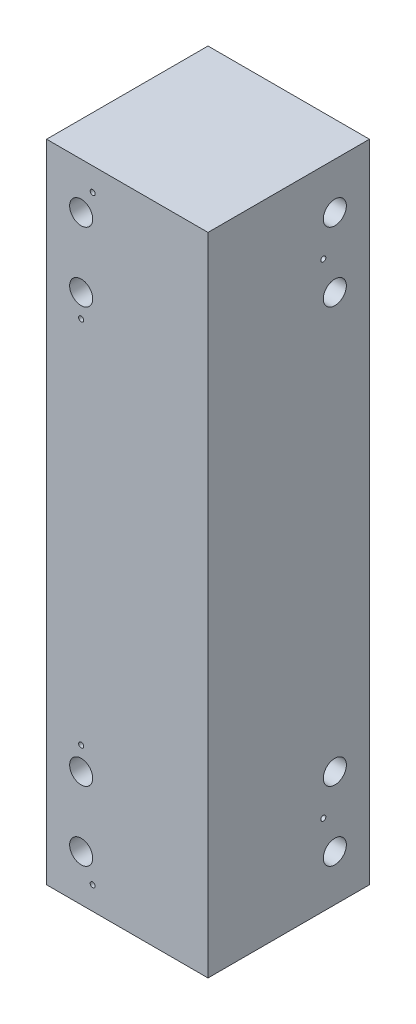
from build123d import *

# Parameters (mm, degrees)
SKETCH1_W                                = 88.9
SKETCH1_H                                = 88.9
BOSS_EXTRUDE1_DEPTH                      = 355.6
SKETCH2_R                                = 1.3890625
CUT_EXTRUDE1_DEPTH                       = 1
CUT_EXTRUDE1_DEPTH_BACK                  = 89.9
SKETCH3_R                                = 1.3890625
CUT_EXTRUDE2_DEPTH                       = 1
CUT_EXTRUDE2_DEPTH_BACK                  = 89.9
F_1_2_0_5_DIAMETER_HOLE1_D               = 12.7
F_1_2_0_5_DIAMETER_HOLE1_DEPTH           = 19.05
F_1_2_0_5_DIAMETER_HOLE1_TIP             = 3.815464931
F_1_2_0_5_DIAMETER_HOLE1_ON_FACE_2_D     = 12.7
F_1_2_0_5_DIAMETER_HOLE1_ON_FACE_2_DEPTH = 19.05
F_1_2_0_5_DIAMETER_HOLE1_ON_FACE_2_TIP   = 3.815464931
F_10_0_1935_DIAMETER_HOLE1_D             = 4.9149
F_10_0_1935_DIAMETER_HOLE1_DEPTH         = 50.8
F_10_0_1935_DIAMETER_HOLE1_TIP           = 1.476584928


with BuildPart() as part:
    # Sketch1 → Boss-Extrude1 (new body)
    with BuildSketch(Plane(origin=(0, 0, 0), x_dir=(1, 0, 0), z_dir=(0, 1, 0))):
        with Locations((44.45, -44.45)):
            Rectangle(SKETCH1_W, SKETCH1_H)
    extrude(amount=BOSS_EXTRUDE1_DEPTH)

    # Sketch2 → Cut-Extrude1 (cut, two sides)
    with BuildSketch(Plane.XY.offset(88.9)) as cut_extrude1_sk:
        with Locations((19.05, 76.2)):
            Circle(SKETCH2_R)
        with Locations((19.05, 279.4)):
            Circle(SKETCH2_R)
        with Locations((25.4, 342.9)):
            Circle(SKETCH2_R)
        with Locations((25.4, 12.7)):
            Circle(SKETCH2_R)
    extrude(amount=CUT_EXTRUDE1_DEPTH, mode=Mode.SUBTRACT)
    extrude(cut_extrude1_sk.sketch, amount=-CUT_EXTRUDE1_DEPTH_BACK, mode=Mode.SUBTRACT)

    # Sketch3 → Cut-Extrude2 (cut, two sides)
    with BuildSketch(Plane.ZY) as cut_extrude2_sk:
        with Locations((25.4, 311.15)):
            Circle(SKETCH3_R)
        with Locations((25.4, 44.45)):
            Circle(SKETCH3_R)
    extrude(amount=CUT_EXTRUDE2_DEPTH, mode=Mode.SUBTRACT)
    extrude(cut_extrude2_sk.sketch, amount=-CUT_EXTRUDE2_DEPTH_BACK, mode=Mode.SUBTRACT)

    # 1/2 (0.5) Diameter Hole1
    with Locations(Plane(origin=(19.05, 292.1, 88.9), x_dir=(1, 0, 0), z_dir=(0, 0, 1))):
        with Locations((0, 0), (0, 38.1), (0, -266.7), (0, -228.6)):
            Hole(F_1_2_0_5_DIAMETER_HOLE1_D / 2, depth=F_1_2_0_5_DIAMETER_HOLE1_DEPTH)
            with Locations((0, 0, -(F_1_2_0_5_DIAMETER_HOLE1_DEPTH + F_1_2_0_5_DIAMETER_HOLE1_TIP / 2))):  # 118° drill point
                Cone(0, F_1_2_0_5_DIAMETER_HOLE1_D / 2, F_1_2_0_5_DIAMETER_HOLE1_TIP, mode=Mode.SUBTRACT)

    # 1/2 (0.5) Diameter Hole1 on face 2
    with Locations(Plane(origin=(88.9, 63.5, 19.05), x_dir=(0, 0, 1), z_dir=(1, 0, 0))):
        with Locations((0, 0), (0, 38.1), (0, -266.7), (0, -228.6)):
            Hole(F_1_2_0_5_DIAMETER_HOLE1_ON_FACE_2_D / 2, depth=F_1_2_0_5_DIAMETER_HOLE1_ON_FACE_2_DEPTH)
            with Locations((0, 0, -(F_1_2_0_5_DIAMETER_HOLE1_ON_FACE_2_DEPTH + F_1_2_0_5_DIAMETER_HOLE1_ON_FACE_2_TIP / 2))):  # 118° drill point
                Cone(0, F_1_2_0_5_DIAMETER_HOLE1_ON_FACE_2_D / 2, F_1_2_0_5_DIAMETER_HOLE1_ON_FACE_2_TIP, mode=Mode.SUBTRACT)

    # #10 (0.1935) Diameter Hole1
    with Locations(Plane(origin=(12.7, 0, 63.5), x_dir=(0, 0, -1), z_dir=(0, -1, 0))):
        with Locations((0, 0), (0, 50.8), (50.8, 50.8), (50.8, 0)):
            Hole(F_10_0_1935_DIAMETER_HOLE1_D / 2, depth=F_10_0_1935_DIAMETER_HOLE1_DEPTH)
            with Locations((0, 0, -(F_10_0_1935_DIAMETER_HOLE1_DEPTH + F_10_0_1935_DIAMETER_HOLE1_TIP / 2))):  # 118° drill point
                Cone(0, F_10_0_1935_DIAMETER_HOLE1_D / 2, F_10_0_1935_DIAMETER_HOLE1_TIP, mode=Mode.SUBTRACT)


solid = part.part
